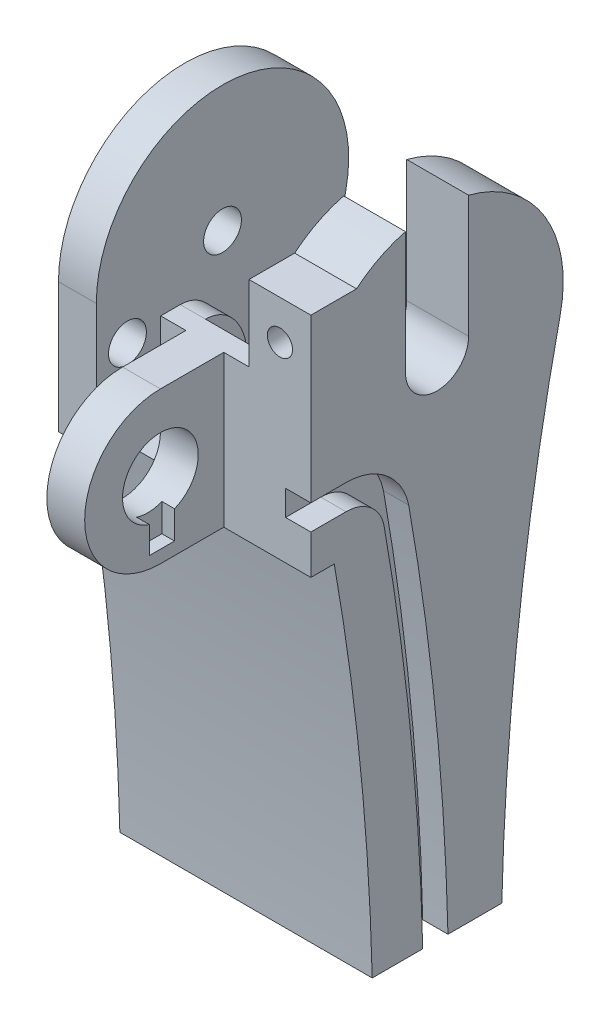
from build123d import *

# Parameters (mm, degrees)
SKETCH1_R                = 1.5
SKETCH1_R_2              = 2.5
BOSS_EXTRUDE1_DEPTH      = 20
SKETCH2_W                = 8.1
SKETCH2_H                = 20
SKETCH2_W_2              = 5.2
SKETCH2_W_3              = 5.1
CUT_EXTRUDE1_DEPTH       = 20
CUT_EXTRUDE1_DEPTH_BACK  = 20
CUT_EXTRUDE2_DEPTH       = 9
BOSS_EXTRUDE2_DEPTH      = 11.9
SKETCH5_R                = 3
BOSS_EXTRUDE3_DEPTH      = 5
CUT_EXTRUDE6_DEPTH       = 1
SKETCH13_R               = 2.5
CUT_EXTRUDE7_DEPTH       = 4
BOSS_EXTRUDE4_DEPTH      = 3
CUT_EXTRUDE9_DEPTH       = 3
SKETCH17_W               = 9
SKETCH17_H               = 3.569322199
CUT_EXTRUDE11_DEPTH      = 3
SKETCH18_W               = 5.770974844
SKETCH18_H               = 0.772936936
BOSS_EXTRUDE5_DEPTH      = 6.9
BOSS_EXTRUDE5_DEPTH_BACK = 1
SKETCH19_W               = 5.1
SKETCH19_H               = 16.397725614
CUT_EXTRUDE12_DEPTH      = 0.301495
SKETCH20_W               = 5
SKETCH20_H               = 12.419235667
CUT_EXTRUDE13_DEPTH      = 10
BOSS_EXTRUDE6_DEPTH      = 2
SKETCH23_W               = 4.9
SKETCH23_H               = 6
BOSS_EXTRUDE7_DEPTH      = 4
SKETCH22_R               = 1
CUT_EXTRUDE15_DEPTH      = 8
BOSS_EXTRUDE8_DEPTH      = 2
SKETCH14_R               = 1.5
CUT_EXTRUDE8_DEPTH       = 10.1
CUT_EXTRUDE17_DEPTH      = 8.1
CUT_EXTRUDE17_DEPTH_BACK = 2
CUT_EXTRUDE18_DEPTH      = 2
CUT_EXTRUDE20_DEPTH      = 5.2
SKETCH30_W               = 6.9
SKETCH30_H               = 20
CUT_EXTRUDE21_DEPTH      = 0.283797
CUT_EXTRUDE22_REACH      = 91.699
SKETCH31_W               = 2
SKETCH31_H               = 11.022421386
CUT_EXTRUDE23_DEPTH      = 7
CUT_EXTRUDE24_DEPTH      = 21
SKETCH34_W               = 60.526432738
SKETCH34_H               = 58.455185991
CUT_EXTRUDE25_DEPTH      = 21


with BuildPart() as part:
    # Sketch1 → Boss-Extrude1 (new body)
    with BuildSketch(Plane(origin=(0, 0, 0), x_dir=(0, 0, -1), z_dir=(1, 0, 0))):
        with BuildLine():
            ThreePointArc((9.765353557, 20.116545894), (0, 32.270117322), (-9.765353557, 20.116545894))
            ThreePointArc((-9.765353557, 20.116545894), (-5.132645827, -18.047253777), (-7.88740095, -56.392382678))
            ThreePointArc((-7.88740095, -56.392382678), (0, -65.729882678), (7.88740095, -56.392382678))
            ThreePointArc((7.88740095, -56.392382678), (5.132645827, -18.047253777), (9.765353557, 20.116545894))
        make_face()
        with Locations((0, 22.270117322)):
            Circle(SKETCH1_R, mode=Mode.SUBTRACT)
        with Locations((0, -57.729882678)):
            Circle(SKETCH1_R_2, mode=Mode.SUBTRACT)
    extrude(amount=BOSS_EXTRUDE1_DEPTH)

    # Sketch2 → Cut-Extrude1 (cut, two sides)
    with BuildSketch(Plane.XY) as cut_extrude1_sk:
        with Locations((4.05, -55.729882678)):
            Rectangle(SKETCH2_W, SKETCH2_H)
        with Locations((17.4, -55.729882678)):
            Rectangle(SKETCH2_W_2, SKETCH2_H)
        with Locations((5.55, 22.270117322)):
            Rectangle(SKETCH2_W_3, SKETCH2_H)
    extrude(amount=CUT_EXTRUDE1_DEPTH, mode=Mode.SUBTRACT)
    extrude(cut_extrude1_sk.sketch, amount=-CUT_EXTRUDE1_DEPTH_BACK, mode=Mode.SUBTRACT)

    # Sketch3 → Cut-Extrude2 (cut)
    with BuildSketch(Plane.ZY.offset(-8.1)):
        with BuildLine():
            Line((8.5, 22.270117322), (8.5, 40.909533312))
            Line((8.5, 40.909533312), (-17.52872033, 40.909533312))
            Line((-17.52872033, 40.909533312), (-17.52872033, 13.770117322))
            Line((-17.52872033, 13.770117322), (0, 13.770117322))
            ThreePointArc((0, 13.770117322), (6.01040764, 16.259709682), (8.5, 22.270117322))
        make_face()
    extrude(amount=-CUT_EXTRUDE2_DEPTH, mode=Mode.SUBTRACT)

    # Sketch4 → Boss-Extrude2 (add, through all)
    with BuildSketch(Plane.ZY.offset(-8.1)):
        Polygon((8.5, 27.537944199), (8.283796844, 12.741558936), (10.283796844, 12.741558936), (10.283796844, 27.537944199), align=None)
    extrude(amount=-BOSS_EXTRUDE2_DEPTH)

    # Sketch5 → Boss-Extrude3 (add)
    with BuildSketch(Plane.ZY.offset(-8.1)):
        with BuildLine():
            Line((8.145156861, 11.968622), (8.447845456, 23.968622))
            Line((8.447845456, 23.968622), (9.854698466, 23.968622))
            Line((9.854698466, 23.968622), (15.022421386, 23.968622))
            ThreePointArc((15.022421386, 23.968622), (21.022421386, 17.968622), (15.022421386, 11.968622))
            Line((15.022421386, 11.968622), (8.145156861, 11.968622))
        make_face()
        with Locations((15.022421386, 17.968622)):
            Circle(SKETCH5_R, mode=Mode.SUBTRACT)
    extrude(amount=-BOSS_EXTRUDE3_DEPTH)

    # Sketch12 → Cut-Extrude6 (cut)
    with BuildSketch(Plane(origin=(13.1, 0, 0), x_dir=(0, 0, -1), z_dir=(1, 0, 0))):
        Polygon((-13.902900694, 14.968622), (-13.902900694, 12.968622), (-15.902900694, 12.968622), (-15.902900694, 14.968622), (-15.902900694, 15.294296094), (-13.902900694, 15.294296094), align=None)
    extrude(amount=-CUT_EXTRUDE6_DEPTH, mode=Mode.SUBTRACT)

    # Sketch13 → Cut-Extrude7 (cut)
    with BuildSketch(Plane.ZY.offset(-17.1)):
        with Locations((0, 22.270117322)):
            Circle(SKETCH13_R)
    extrude(amount=-CUT_EXTRUDE7_DEPTH, mode=Mode.SUBTRACT)

    # Sketch15 → Boss-Extrude4 (add)
    with BuildSketch(Plane.ZY):
        Polygon((10, 22.270117322), (10, 11.968622), (8.145156861, 11.968622), (7.595672539, 11.968622), align=None)
    extrude(amount=-BOSS_EXTRUDE4_DEPTH)

    # Sketch16 → Cut-Extrude9 (cut)
    with BuildSketch(Plane(origin=(20, 0, 0), x_dir=(0, 0, -1), z_dir=(1, 0, 0))):
        with BuildLine():
            Line((-10.283796844, 23.968622), (-9.854698466, 23.968622))
            ThreePointArc((-9.854698466, 23.968622), (-9.349264901, 25.818531871), (-8.5, 27.537944199))
            Line((-8.5, 27.537944199), (-10.283796844, 27.537944199))
            Line((-10.283796844, 27.537944199), (-10.283796844, 23.968622))
        make_face()
    extrude(amount=-CUT_EXTRUDE9_DEPTH, mode=Mode.SUBTRACT)

    # Sketch17 → Cut-Extrude11 (cut)
    with BuildSketch(Plane.XY.offset(10.283796844)):
        with Locations((12.6, 25.7532831)):
            Rectangle(SKETCH17_W, SKETCH17_H)
    extrude(amount=-CUT_EXTRUDE11_DEPTH, mode=Mode.SUBTRACT)

    # Sketch18 → Boss-Extrude5 (add, two sides)
    with BuildSketch(Plane(origin=(13.1, 0, 0), x_dir=(0, 0, -1), z_dir=(1, 0, 0))) as boss_extrude5_sk:
        with Locations((-7.398309422, 12.355090468)):
            Rectangle(SKETCH18_W, SKETCH18_H)
    extrude(amount=BOSS_EXTRUDE5_DEPTH)
    extrude(boss_extrude5_sk.sketch, amount=-BOSS_EXTRUDE5_DEPTH_BACK)

    # Sketch19 → Cut-Extrude12 (cut)
    with BuildSketch(Plane(origin=(0, 12.270117322, 0), x_dir=(1, 0, 0), z_dir=(0, 1, 0))):
        with Locations((5.55, 0)):
            Rectangle(SKETCH19_W, SKETCH19_H)
    extrude(amount=-CUT_EXTRUDE12_DEPTH, mode=Mode.SUBTRACT)

    # Sketch20 → Cut-Extrude13 (cut)
    with BuildSketch(Plane.ZY.offset(-17.1)):
        with Locations((0, 28.479735156)):
            Rectangle(SKETCH20_W, SKETCH20_H)
    extrude(amount=-CUT_EXTRUDE13_DEPTH, mode=Mode.SUBTRACT)

    # Sketch21 → Boss-Extrude6 (add)
    with BuildSketch(Plane.ZY.offset(-17.1)):
        with BuildLine():
            Line((-8.473151119, 13.770117322), (0.278481736, 12.273995678))
            ThreePointArc((0.278481736, 12.273995678), (9.936881703, 21.148341047), (2.5, 31.952575688))
            Line((2.5, 31.952575688), (2.5, 22.270117322))
            ThreePointArc((2.5, 22.270117322), (0, 19.770117322), (-2.5, 22.270117322))
            Line((-2.5, 22.270117322), (-2.5, 31.952575688))
            ThreePointArc((-2.5, 31.952575688), (-8.522477621, 27.501501002), (-9.765353557, 20.116545894))
            ThreePointArc((-9.765353557, 20.116545894), (-9.093560923, 16.948562662), (-8.473151119, 13.770117322))
        make_face()
    extrude(amount=BOSS_EXTRUDE6_DEPTH)

    # Sketch23 → Boss-Extrude7 (add)
    with BuildSketch(Plane.XY.offset(10.283796844)):
        with Locations((17.55, 26.968622)):
            Rectangle(SKETCH23_W, SKETCH23_H)
    extrude(amount=-BOSS_EXTRUDE7_DEPTH)

    # Sketch22 → Cut-Extrude15 (cut)
    with BuildSketch(Plane.XY.offset(10.283796844)):
        with Locations((17.55, 26.870117322)):
            Circle(SKETCH22_R)
    extrude(amount=-CUT_EXTRUDE15_DEPTH, mode=Mode.SUBTRACT)

    # Sketch24 → Boss-Extrude8 (add)
    with BuildSketch(Plane.ZY.offset(-8.1)):
        with BuildLine():
            Line((5.147845456, 19.737443909), (5.147845456, 15.506265819))
            Line((5.147845456, 15.506265819), (8.447845456, 15.506265819))
            Line((8.447845456, 15.506265819), (8.447845456, 23.968622))
            add(Edge.make_bspline(
                [(8.447845456, 23.968622), (5.147845456, 23.968622), (5.147845456, 19.737443909)],
                knots=[3.141592654, 3.141592654, 3.141592654, 4.71238898, 4.71238898, 4.71238898], degree=2, weights=[1, 0.707106781, 1]))
        make_face()
    extrude(amount=-BOSS_EXTRUDE8_DEPTH)

    # Sketch14 → Cut-Extrude8 (cut)
    with BuildSketch(Plane.ZY):
        with Locations((7.532575614, 18.331804915)):
            Circle(SKETCH14_R)
    extrude(amount=-CUT_EXTRUDE8_DEPTH, mode=Mode.SUBTRACT)

    # Sketch25 → Cut-Extrude17 (cut, two sides)
    with BuildSketch(Plane.ZY.offset(-8.1)) as cut_extrude17_sk:
        with BuildLine():
            Line((12, -45.729882678), (8.346153846, -36.960651908))
            ThreePointArc((8.346153846, -36.960651908), (6.973852263, -42.37911752), (2.5, -45.729882678))
            Line((2.5, -45.729882678), (2.5, -53.227383372))
            ThreePointArc((2.5, -53.227383372), (0, -62.879882678), (-2.5, -53.227383372))
            Line((-2.5, -53.227383372), (-2.5, -45.729882678))
            ThreePointArc((-2.5, -45.729882678), (-6.973852263, -42.37911752), (-8.346153846, -36.960651908))
            Line((-8.346153846, -36.960651908), (-12, -45.729882678))
            Line((-12, -45.729882678), (-12, -57.729882678))
            ThreePointArc((-12, -57.729882678), (0, -69.729882678), (12, -57.729882678))
            Line((12, -57.729882678), (12, -45.729882678))
        make_face()
    extrude(amount=CUT_EXTRUDE17_DEPTH, mode=Mode.SUBTRACT)
    extrude(cut_extrude17_sk.sketch, amount=-CUT_EXTRUDE17_DEPTH_BACK, mode=Mode.SUBTRACT)

    # Sketch26 → Cut-Extrude18 (cut)
    with BuildSketch(Plane(origin=(20, 0, 0), x_dir=(0, 0, -1), z_dir=(1, 0, 0))):
        with BuildLine():
            Line((-7.209968303, 15.085404497), (-10.283796844, 15.085404497))
            Line((-10.283796844, 15.085404497), (-10.283796844, 17.085404497))
            Line((-10.283796844, 17.085404497), (-7.209968303, 17.085404497))
            ThreePointArc((-7.209968303, 17.085404497), (-4.010444351, 15.949526558), (-2.243391617, 13.050441039))
            ThreePointArc((-2.243391617, 13.050441039), (0.649659998, -12.257973546), (0.397031114, -37.729953741))
            Line((0.397031114, -37.729953741), (-1.608183929, -37.729953741))
            ThreePointArc((-1.608183929, -37.729953741), (-1.343036313, -12.450773719), (-4.206611504, 12.667092093))
            ThreePointArc((-4.206611504, 12.667092093), (-5.281990934, 14.405678614), (-7.209968303, 15.085404497))
        make_face()
    extrude(amount=-CUT_EXTRUDE18_DEPTH, mode=Mode.SUBTRACT)

    # Sketch29 → Cut-Extrude20 (cut)
    with BuildSketch(Plane(origin=(20, 0, 0), x_dir=(0, 0, -1), z_dir=(1, 0, 0))):
        with BuildLine():
            Line((8, -37.729882678), (8.140336581, -37.729882678))
            Line((8.140336581, -37.729882678), (8.140336581, -45.937498976))
            Line((8.140336581, -45.937498976), (-15.754893946, -45.937498976))
            Line((-15.754893946, -45.937498976), (-15.754893946, -37.729882678))
            Line((-15.754893946, -37.729882678), (-8, -37.729882678))
            ThreePointArc((-8, -37.729882678), (0, -45.729882678), (8, -37.729882678))
        make_face()
    extrude(amount=-CUT_EXTRUDE20_DEPTH, mode=Mode.SUBTRACT)

    # Sketch30 → Cut-Extrude21 (cut)
    with BuildSketch(Plane.XY.offset(10.283796844)):
        with Locations((16.55, 21.968622)):
            Rectangle(SKETCH30_W, SKETCH30_H)
    extrude(amount=-CUT_EXTRUDE21_DEPTH, mode=Mode.SUBTRACT)

    # Sketch31 → Cut-Extrude22 (cut, up to next)
    with BuildSketch(Plane(origin=(0, 23.968622, 0), x_dir=(1, 0, 0), z_dir=(0, 1, 0)), mode=Mode.PRIVATE) as cut_extrude22_sk1:
        with Locations((9.1, -15.511210693)):
            Rectangle(SKETCH31_W, SKETCH31_H)
    cut_extrude22_tool1 = extrude(cut_extrude22_sk1.sketch, amount=-CUT_EXTRUDE22_REACH, mode=Mode.PRIVATE) & part.part
    add(cut_extrude22_tool1.solids().sort_by_distance((9.1, 23.968622, 15.511211))[0], mode=Mode.SUBTRACT)

    # Sketch32 → Cut-Extrude23 (cut)
    with BuildSketch(Plane.ZY.offset(-8.1)):
        Polygon((-8.473151119, 13.770117322), (-8.473151119, 5.401068454), (5.147845456, 15.506265819), align=None)
    extrude(amount=-CUT_EXTRUDE23_DEPTH, mode=Mode.SUBTRACT)

    # Sketch33 → Cut-Extrude24 (cut, through all)
    with BuildSketch(Plane(origin=(20, 0, 0), x_dir=(0, 0, -1), z_dir=(1, 0, 0))):
        Polygon((-9.30475326, -22.954882678), (-9.30475326, -27.954882678), (8.892389241, -27.954882678), (8.892389241, -22.954882678), (8.892389241, -17.954882678), (-9.30475326, -17.954882678), align=None)
    extrude(amount=-CUT_EXTRUDE24_DEPTH, mode=Mode.SUBTRACT)

    # Sketch34 → Cut-Extrude25 (cut, through all)
    with BuildSketch(Plane(origin=(20, 0, 0), x_dir=(0, 0, -1), z_dir=(1, 0, 0))):
        with Locations((-5.515206789, -53.322694673)):
            Rectangle(SKETCH34_W, SKETCH34_H)
    extrude(amount=-CUT_EXTRUDE25_DEPTH, mode=Mode.SUBTRACT)


solid = part.part
